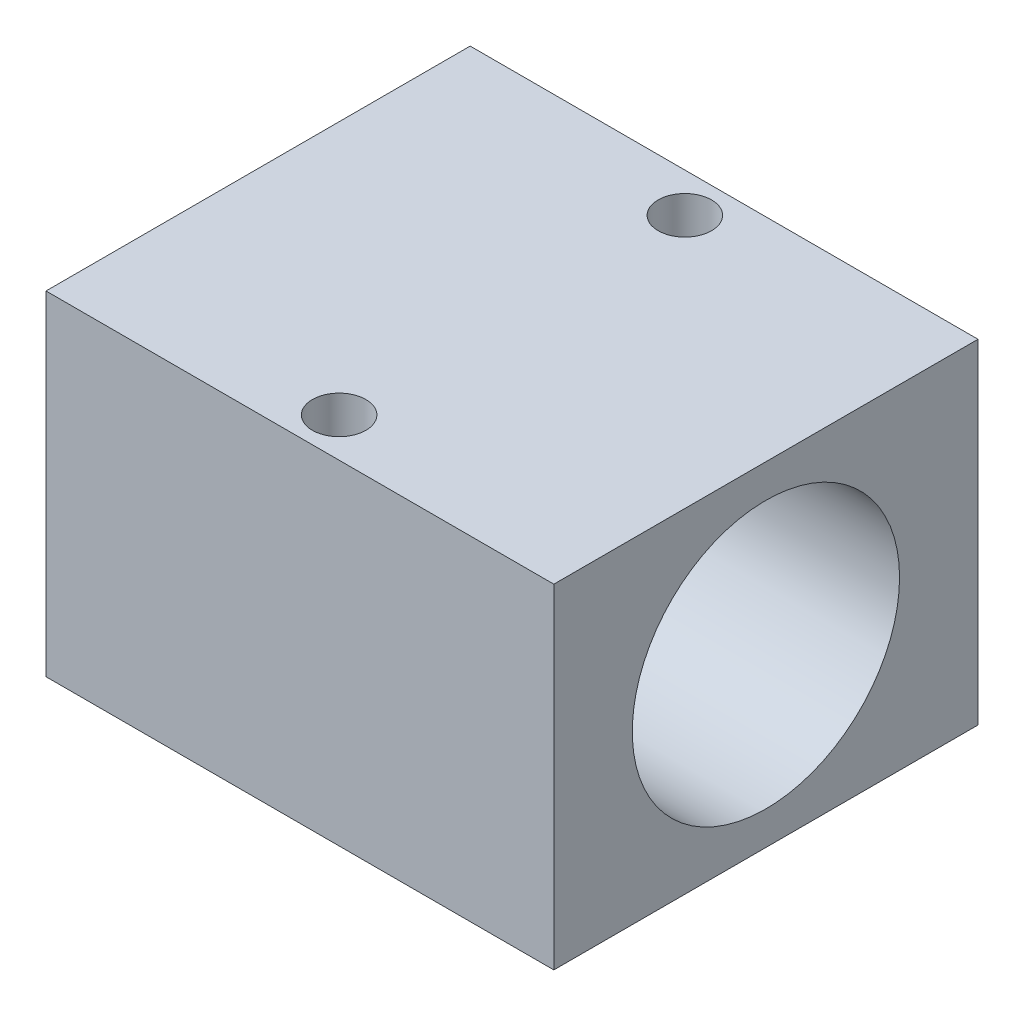
from build123d import *

# Parameters (mm, degrees)
SKETCH1_W          = 19
SKETCH1_H          = 15.87
EXTRUDE1_DEPTH     = 12.5
SKETCH2_R          = 5
CUT_EXTRUDE1_DEPTH = 22.5
SKETCH3_R          = 1
CUT_EXTRUDE2_DEPTH = 22.5


with BuildPart() as part:
    # Sketch1 → Extrude1 (new body)
    with BuildSketch(Plane(origin=(0, 0, 0), x_dir=(1, 0, 0), z_dir=(0, 1, 0))):
        Rectangle(SKETCH1_W, SKETCH1_H)
    extrude(amount=EXTRUDE1_DEPTH)

    # Sketch2 → Cut-Extrude1 (cut)
    with BuildSketch(Plane(origin=(9.5, 0, 0), x_dir=(0, 0, -1), z_dir=(1, 0, 0))):
        with Locations((0, 6.25)):
            Circle(SKETCH2_R)
    extrude(amount=-CUT_EXTRUDE1_DEPTH, mode=Mode.SUBTRACT)

    # Sketch3 → Cut-Extrude2 (cut)
    with BuildSketch(Plane(origin=(0, 12.5, 0), x_dir=(1, 0, 0), z_dir=(0, 1, 0))):
        with Locations(Location((0, -6.4675, 0), (0, 0, 270))):  # turned: the seam where the file's is
            Circle(SKETCH3_R)
        with Locations(Location((0, 6.4675, 0), (0, 0, 90))):  # turned: the seam where the file's is
            Circle(SKETCH3_R)
    extrude(amount=-CUT_EXTRUDE2_DEPTH, mode=Mode.SUBTRACT)


solid = part.part
